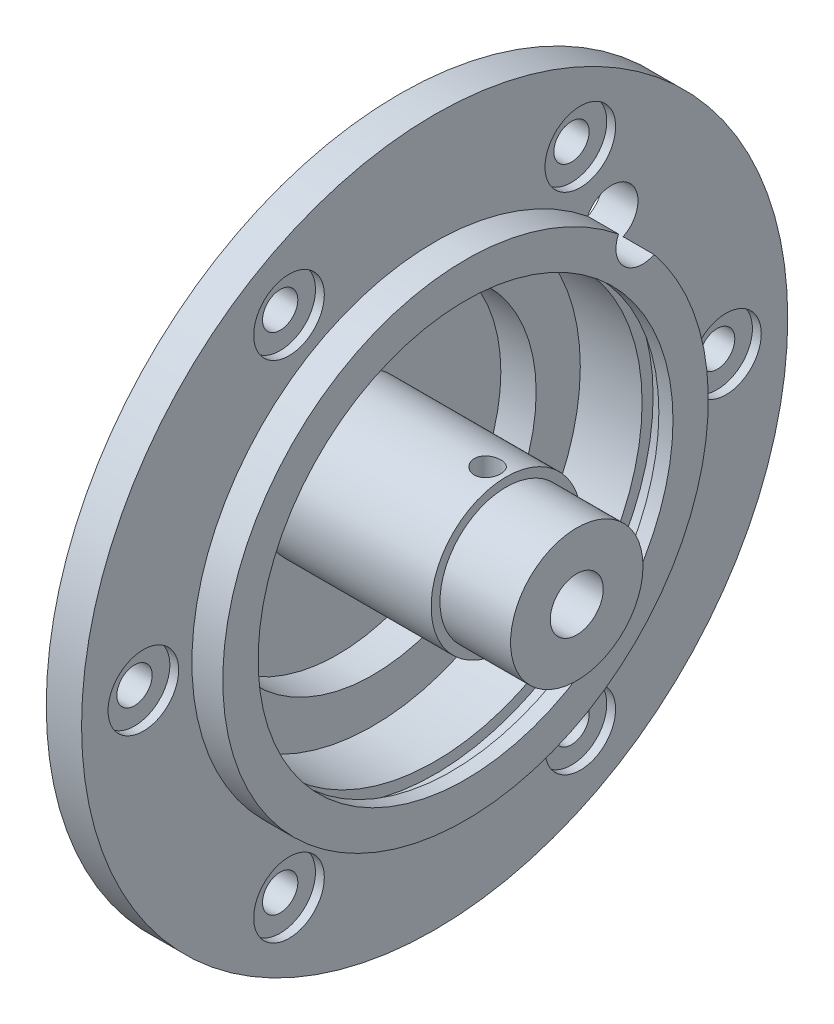
from build123d import *

# Parameters (mm, degrees)
SKETCH1_R                = 40
BOSS_EXTRUDE1_DEPTH      = 27
SKETCH2_R                = 3
CUT_EXTRUDE1_DEPTH       = 1
CUT_EXTRUDE1_DEPTH_BACK  = 45
SKETCH3_R                = 18.5
SKETCH3_R_2              = 8.5
CUT_EXTRUDE2_DEPTH       = 23
SKETCH4_R                = 23.5
SKETCH4_R_2              = 18.5
CUT_EXTRUDE5_DEPTH       = 19
SKETCH6_R                = 40
SKETCH6_R_2              = 22.5
CUT_EXTRUDE6_DEPTH       = 4
SKETCH7_R                = 40
SKETCH7_R_2              = 27.5
CUT_EXTRUDE7_DEPTH       = 12
SKETCH8_R                = 35
SKETCH8_R_2              = 8.5
CUT_EXTRUDE8_DEPTH       = 8.5
SKETCH9_R                = 24.75
SKETCH9_R_2              = 8.5
CUT_EXTRUDE13_DEPTH      = 0.95
SKETCH10_R               = 3
CUT_EXTRUDE14_DEPTH      = 13
CUT_EXTRUDE14_DEPTH_BACK = 16
SKETCH11_R               = 2
CUT_EXTRUDE22_DEPTH      = 11
SKETCH12_R               = 4
CUT_EXTRUDE23_DEPTH      = 1
CIRPATTERN1_COUNT        = 6
CUT_EXTRUDE24_REACH      = 42
SKETCH13_R               = 1.5
SKETCH14_R               = 40
SKETCH14_R_2             = 27
CUT_EXTRUDE25_DEPTH      = 7
CUT_EXTRUDE26_REACH      = 42
SKETCH15_R               = 1.5
SKETCH16_R               = 8.5
BOSS_EXTRUDE2_DEPTH      = 4.1
SKETCH17_R               = 8.5
SKETCH17_R_2             = 7.5
CUT_EXTRUDE27_DEPTH      = 8
SKETCH18_R               = 3
CUT_EXTRUDE28_DEPTH      = 7


with BuildPart() as part:
    # Sketch1 → Boss-Extrude1 (new body)
    with BuildSketch(Plane(origin=(0, 0, 0), x_dir=(0, 0, -1), z_dir=(1, 0, 0))):
        Circle(SKETCH1_R)
    extrude(amount=BOSS_EXTRUDE1_DEPTH)

    # Sketch2 → Cut-Extrude1 (cut, two sides)
    with BuildSketch(Plane.ZY) as cut_extrude1_sk:
        Circle(SKETCH2_R)
    extrude(amount=CUT_EXTRUDE1_DEPTH, mode=Mode.SUBTRACT)
    extrude(cut_extrude1_sk.sketch, amount=-CUT_EXTRUDE1_DEPTH_BACK, mode=Mode.SUBTRACT)

    # Sketch3 → Cut-Extrude2 (cut)
    with BuildSketch(Plane(origin=(27, 0, 0), x_dir=(0, 0, -1), z_dir=(1, 0, 0))):
        Circle(SKETCH3_R)
        Circle(SKETCH3_R_2, mode=Mode.SUBTRACT)
    extrude(amount=-CUT_EXTRUDE2_DEPTH, mode=Mode.SUBTRACT)

    # Sketch4 → Cut-Extrude5 (cut)
    with BuildSketch(Plane(origin=(27, 0, 0), x_dir=(0, 0, -1), z_dir=(1, 0, 0))):
        Circle(SKETCH4_R)
        Circle(SKETCH4_R_2, mode=Mode.SUBTRACT)
    extrude(amount=-CUT_EXTRUDE5_DEPTH, mode=Mode.SUBTRACT)

    # Sketch6 → Cut-Extrude6 (cut)
    with BuildSketch(Plane.ZY):
        Circle(SKETCH6_R)
        Circle(SKETCH6_R_2, mode=Mode.SUBTRACT)
    extrude(amount=-CUT_EXTRUDE6_DEPTH, mode=Mode.SUBTRACT)

    # Sketch7 → Cut-Extrude7 (cut)
    with BuildSketch(Plane(origin=(27, 0, 0), x_dir=(0, 0, -1), z_dir=(1, 0, 0))):
        Circle(SKETCH7_R)
        Circle(SKETCH7_R_2, mode=Mode.SUBTRACT)
    extrude(amount=-CUT_EXTRUDE7_DEPTH, mode=Mode.SUBTRACT)

    # Sketch8 → Cut-Extrude8 (cut)
    with BuildSketch(Plane(origin=(27, 0, 0), x_dir=(0, 0, -1), z_dir=(1, 0, 0))):
        Circle(SKETCH8_R)
        Circle(SKETCH8_R_2, mode=Mode.SUBTRACT)
    extrude(amount=-CUT_EXTRUDE8_DEPTH, mode=Mode.SUBTRACT)

    # Sketch9 → Cut-Extrude13 (cut, symmetric)
    with BuildSketch(Plane(origin=(15.95, 0, 0), x_dir=(0, 0, -1), z_dir=(1, 0, 0))):
        Circle(SKETCH9_R)
        Circle(SKETCH9_R_2, mode=Mode.SUBTRACT)
    extrude(amount=CUT_EXTRUDE13_DEPTH, both=True, mode=Mode.SUBTRACT)

    # Sketch10 → Cut-Extrude14 (cut, two sides)
    with BuildSketch(Plane(origin=(15, 0, 0), x_dir=(0, 0, -1), z_dir=(1, 0, 0))) as cut_extrude14_sk:
        with Locations((20.032335111, 20.032335111)):
            Circle(SKETCH10_R)
    extrude(amount=CUT_EXTRUDE14_DEPTH, mode=Mode.SUBTRACT)
    extrude(cut_extrude14_sk.sketch, amount=-CUT_EXTRUDE14_DEPTH_BACK, mode=Mode.SUBTRACT)

    # Sketch11 → Cut-Extrude22 (cut)
    with BuildSketch(Plane(origin=(15, 0, 0), x_dir=(0, 0, -1), z_dir=(1, 0, 0))):
        with Locations((33, 0)):
            Circle(SKETCH11_R)
    cut_extrude22 = extrude(amount=-CUT_EXTRUDE22_DEPTH, mode=Mode.SUBTRACT)

    # Sketch12 → Cut-Extrude23 (cut)
    with BuildSketch(Plane(origin=(15, 0, 0), x_dir=(0, 0, -1), z_dir=(1, 0, 0))):
        with Locations((33, 0)):
            Circle(SKETCH12_R)
    cut_extrude23 = extrude(amount=-CUT_EXTRUDE23_DEPTH, mode=Mode.SUBTRACT)

    # CirPattern1: Cut-Extrude22, Cut-Extrude23 ×6 about axis
    cirpattern1_axis = Axis((0, 0, 0), (1, 0, 0))
    for i in range(1, CIRPATTERN1_COUNT):
        add(cut_extrude22.rotate(cirpattern1_axis, i * 360 / CIRPATTERN1_COUNT), mode=Mode.SUBTRACT)
        add(cut_extrude23.rotate(cirpattern1_axis, i * 360 / CIRPATTERN1_COUNT), mode=Mode.SUBTRACT)

    # Sketch13 → Cut-Extrude24 (cut, up to next)
    with BuildSketch(Plane(origin=(0, 0, 0), x_dir=(1, 0, 0), z_dir=(0, 1, 0)), mode=Mode.PRIVATE) as cut_extrude24_sk1:
        with Locations((21, 0)):
            Circle(SKETCH13_R)
    cut_extrude24_tool1 = extrude(cut_extrude24_sk1.sketch, amount=CUT_EXTRUDE24_REACH, mode=Mode.PRIVATE) & part.part
    add(cut_extrude24_tool1.solids().sort_by_distance((21, 0, 0))[0], mode=Mode.SUBTRACT)

    # Sketch14 → Cut-Extrude25 (cut)
    with BuildSketch(Plane.ZY.offset(-4)):
        Circle(SKETCH14_R)
        Circle(SKETCH14_R_2, mode=Mode.SUBTRACT)
    extrude(amount=-CUT_EXTRUDE25_DEPTH, mode=Mode.SUBTRACT)

    # Sketch15 → Cut-Extrude26 (cut, up to next)
    with BuildSketch(Plane.XY, mode=Mode.PRIVATE) as cut_extrude26_sk1:
        with Locations((21, 0)):
            Circle(SKETCH15_R)
    cut_extrude26_tool1 = extrude(cut_extrude26_sk1.sketch, amount=-CUT_EXTRUDE26_REACH, mode=Mode.PRIVATE) & part.part
    add(cut_extrude26_tool1.solids().sort_by_distance((21, 0, 0))[0], mode=Mode.SUBTRACT)

    # Sketch16 → Boss-Extrude2 (add)
    with BuildSketch(Plane(origin=(27, 0, 0), x_dir=(0, 0, -1), z_dir=(1, 0, 0))):
        Circle(SKETCH16_R)
    extrude(amount=BOSS_EXTRUDE2_DEPTH)

    # Sketch17 → Cut-Extrude27 (cut)
    with BuildSketch(Plane(origin=(31.1, 0, 0), x_dir=(0, 0, -1), z_dir=(1, 0, 0))):
        Circle(SKETCH17_R)
        Circle(SKETCH17_R_2, mode=Mode.SUBTRACT)
    extrude(amount=-CUT_EXTRUDE27_DEPTH, mode=Mode.SUBTRACT)

    # Sketch18 → Cut-Extrude28 (cut)
    with BuildSketch(Plane(origin=(31.1, 0, 0), x_dir=(0, 0, -1), z_dir=(1, 0, 0))):
        Circle(SKETCH18_R)
    extrude(amount=-CUT_EXTRUDE28_DEPTH, mode=Mode.SUBTRACT)


solid = part.part
